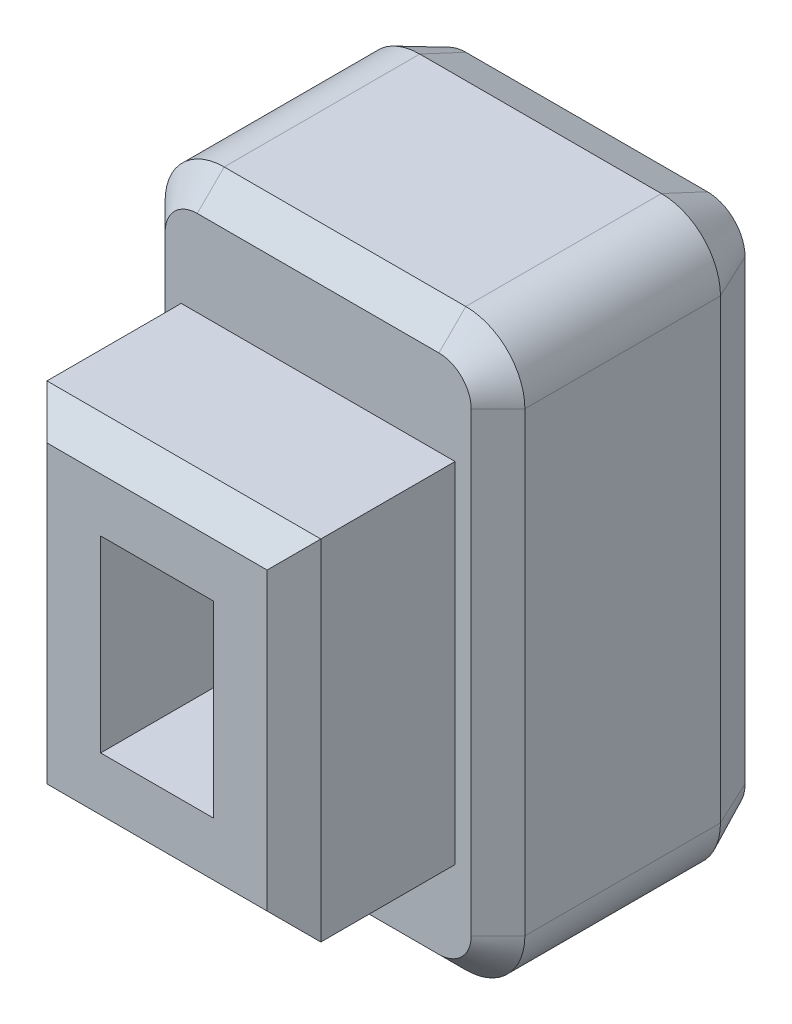
from build123d import *

# Parameters (mm, degrees)
BOSS_EXTRU_1_DEPTH      = 8
CHANFREIN1_SIZE         = 0.4
CHANFREIN1_SIZE2        = 0.857802768
ESQUISSE3_W             = 2.1
ESQUISSE3_H             = 3.5
ENL_V_MAT_EXTRU_4_DEPTH = 3
ESQUISSE4_OUTSIDE_W     = 11.69
ESQUISSE4_OUTSIDE_H     = 15.69
ESQUISSE4_OUTSIDE_W_2   = 5.1
ESQUISSE4_OUTSIDE_H_2   = 6.5
ENL_V_MAT_EXTRU_5_DEPTH = 3
CHANFREIN2_SIZE         = 0.5
BOSS_EXTRU_2_DEPTH      = 0.2
ENL_V_MAT_EXTRU_6_DEPTH = 0.2


with BuildPart() as part:
    # Esquisse2 → Boss.-Extru.1 (new body)
    with BuildSketch(Plane.XY):
        with BuildLine():
            Line((1.1, 0), (5.6, 0))
            ThreePointArc((5.6, 0), (6.377817459, 0.322182541), (6.7, 1.1))
            Line((6.7, 1.1), (6.7, 9.6))
            ThreePointArc((6.7, 9.6), (6.377817459, 10.377817459), (5.6, 10.7))
            Line((5.6, 10.7), (1.1, 10.7))
            ThreePointArc((1.1, 10.7), (0.322182541, 10.377817459), (0, 9.6))
            Line((0, 9.6), (0, 1.1))
            ThreePointArc((0, 1.1), (0.322182541, 0.322182541), (1.1, 0))
        make_face()
    extrude(amount=BOSS_EXTRU_1_DEPTH)

    # Chanfrein1
    chanfrein1_edges = [part.edges().sort_by_distance(p)[0] for p in [
        (3.35, 0, 0),
        (6.377817459, 0.322182541, 0),
        (0.322182541, 0.322182541, 0),
        (6.7, 5.35, 0),
        (0, 5.35, 0),
        (6.377817459, 10.377817459, 0),
        (0.322182541, 10.377817459, 0),
        (3.35, 10.7, 0),
    ]]
    chanfrein1_side = [part.faces().sort_by_distance(p)[0] for p in [
        (3.35, 5.35, 0),
    ]]
    chamfer(chanfrein1_edges, length=CHANFREIN1_SIZE, length2=CHANFREIN1_SIZE2, reference=chanfrein1_side[0])

    # Esquisse3 → Enl_v. mat.-Extru.4 (cut)
    with BuildSketch(Plane.XY.offset(8)):
        with Locations((3.35, 5.35)):
            Rectangle(ESQUISSE3_W, ESQUISSE3_H)
    extrude(amount=-ENL_V_MAT_EXTRU_4_DEPTH, mode=Mode.SUBTRACT)

    # Esquisse4 outside → Enl_v. mat.-Extru.5 (cut)
    with BuildSketch(Plane.XY.offset(8)):
        with Locations((3.35, 5.35)):
            Rectangle(ESQUISSE4_OUTSIDE_W, ESQUISSE4_OUTSIDE_H)
        with Locations((3.35, 5.35)):
            Rectangle(ESQUISSE4_OUTSIDE_W_2, ESQUISSE4_OUTSIDE_H_2, mode=Mode.SUBTRACT)
    extrude(amount=-ENL_V_MAT_EXTRU_5_DEPTH, mode=Mode.SUBTRACT)

    # Chanfrein2
    chanfrein2_edges = [part.edges().sort_by_distance(p)[0] for p in [
        (6.7, 5.35, 5),
        (6.377817459, 10.377817459, 5),
        (6.377817459, 0.322182541, 5),
        (3.35, 10.7, 5),
        (3.35, 0, 5),
        (0.322182541, 10.377817459, 5),
        (0.322182541, 0.322182541, 5),
        (0, 5.35, 5),
        (5.9, 5.35, 8),
        (3.35, 8.6, 8),
        (0.8, 5.35, 8),
        (3.35, 2.1, 8),
    ]]
    chamfer(chanfrein2_edges, length=CHANFREIN2_SIZE)

    # Esquisse5 → Boss.-Extru.2 (add)
    with BuildSketch(Plane(origin=(0, 0, 0), x_dir=(-1, 0, 0), z_dir=(0, 0, -1))):
        Polygon((-3.375, 5.112187571), (-2.775, 6.112187571), (-3.175, 6.112187571), (-3.175, 8.848759861), (-2.775, 8.848759861), (-3.375, 9.848759861), (-3.975, 8.848759861), (-3.575, 8.848759861), (-3.575, 6.112187571), (-4.005, 6.112187571), align=None)
        Polygon((-1.779487179, 1.007498111), (-2.450460737, 1.007498111), (-3.35, 3.493675996), (-4.251642628, 1.007498111), (-4.920512821, 1.007498111), (-3.651482372, 4.507498111), (-3.046414263, 4.507498111), align=None)
    extrude(amount=BOSS_EXTRU_2_DEPTH)

    # Esquisse5_2 → Enl_v. mat.-Extru.6 (cut)
    with BuildSketch(Plane(origin=(0, 0, 0), x_dir=(-1, 0, 0), z_dir=(0, 0, -1))):
        Polygon((-3.375, 5.112187571), (-2.775, 6.112187571), (-3.175, 6.112187571), (-3.175, 8.848759861), (-2.775, 8.848759861), (-3.375, 9.848759861), (-3.975, 8.848759861), (-3.575, 8.848759861), (-3.575, 6.112187571), (-4.005, 6.112187571), align=None)
        Polygon((-1.779487179, 1.007498111), (-2.450460737, 1.007498111), (-3.35, 3.493675996), (-4.251642628, 1.007498111), (-4.920512821, 1.007498111), (-3.651482372, 4.507498111), (-3.046414263, 4.507498111), align=None)
    extrude(amount=-ENL_V_MAT_EXTRU_6_DEPTH, mode=Mode.SUBTRACT)


with BuildPart() as enl_v_mat_extru_6_piece_1:
    # of the separate pieces the step leaves, piece 1, a body of its own (enl_v_mat_extru_6_pieces)
    add(part.part.solids().sort_by_distance((0, 1.1, 4.5))[0])


with BuildPart() as enl_v_mat_extru_6_piece_2:
    # of the separate pieces the step leaves, piece 2, a body of its own (enl_v_mat_extru_6_pieces)
    add(part.part.solids().sort_by_distance((1.779487179, 1.007498111, -0.2))[0])


with BuildPart() as enl_v_mat_extru_6_piece_3:
    # of the separate pieces the step leaves, piece 3, a body of its own (enl_v_mat_extru_6_pieces)
    add(part.part.solids().sort_by_distance((4.005, 6.112187571, -0.2))[0])


solid = Compound([enl_v_mat_extru_6_piece_1.part, enl_v_mat_extru_6_piece_2.part, enl_v_mat_extru_6_piece_3.part])
